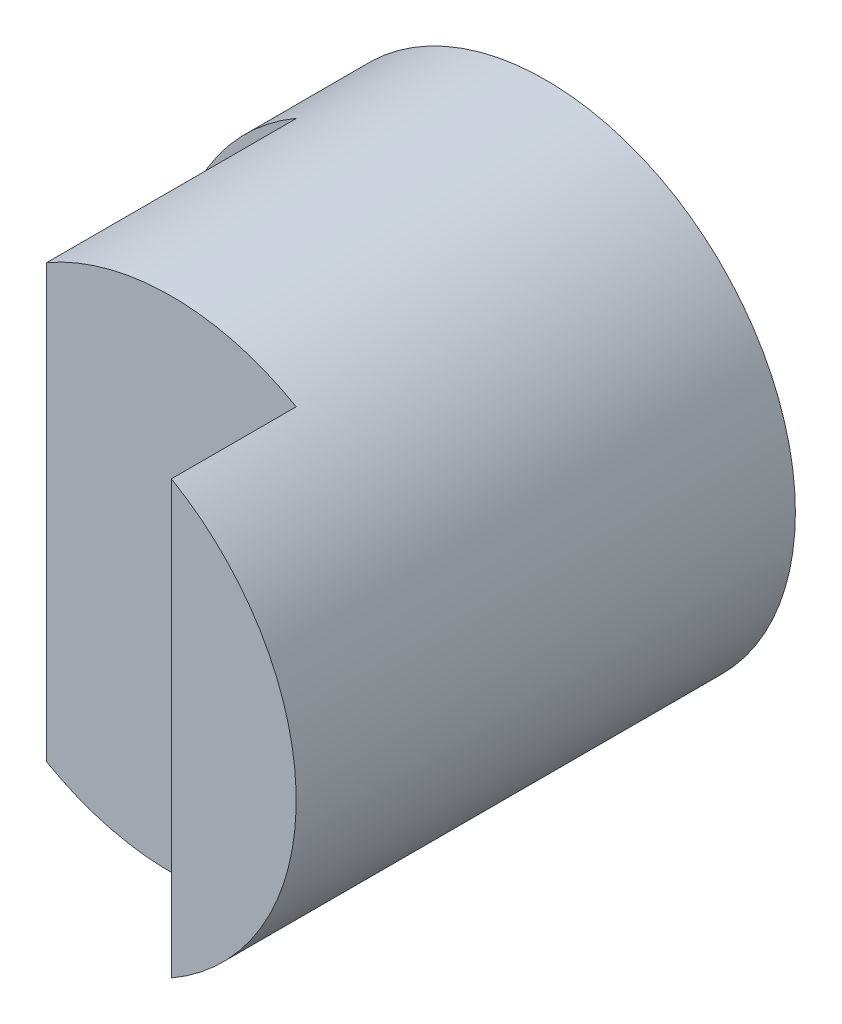
from build123d import *

# Parameters (mm, degrees)
SKETCH1_R           = 2
BOSS_EXTRUDE1_DEPTH = 4
CUT_EXTRUDE2_DEPTH  = 2


with BuildPart() as part:
    # Sketch1 → Boss-Extrude1 (new body)
    with BuildSketch(Plane.XY):
        Circle(SKETCH1_R)
    extrude(amount=BOSS_EXTRUDE1_DEPTH)

    # Sketch2 → Cut-Extrude2 (cut, symmetric)
    with BuildSketch(Plane(origin=(0, 0, 0), x_dir=(1, 0, 0), z_dir=(0, 1, 0))):
        Polygon((-1, -5), (1, -5), (1, -3), (-1, -3), (-1, -0.996424707), (-2, -0.996424707), (-2, -5), align=None)
    extrude(amount=CUT_EXTRUDE2_DEPTH, both=True, mode=Mode.SUBTRACT)


solid = part.part
